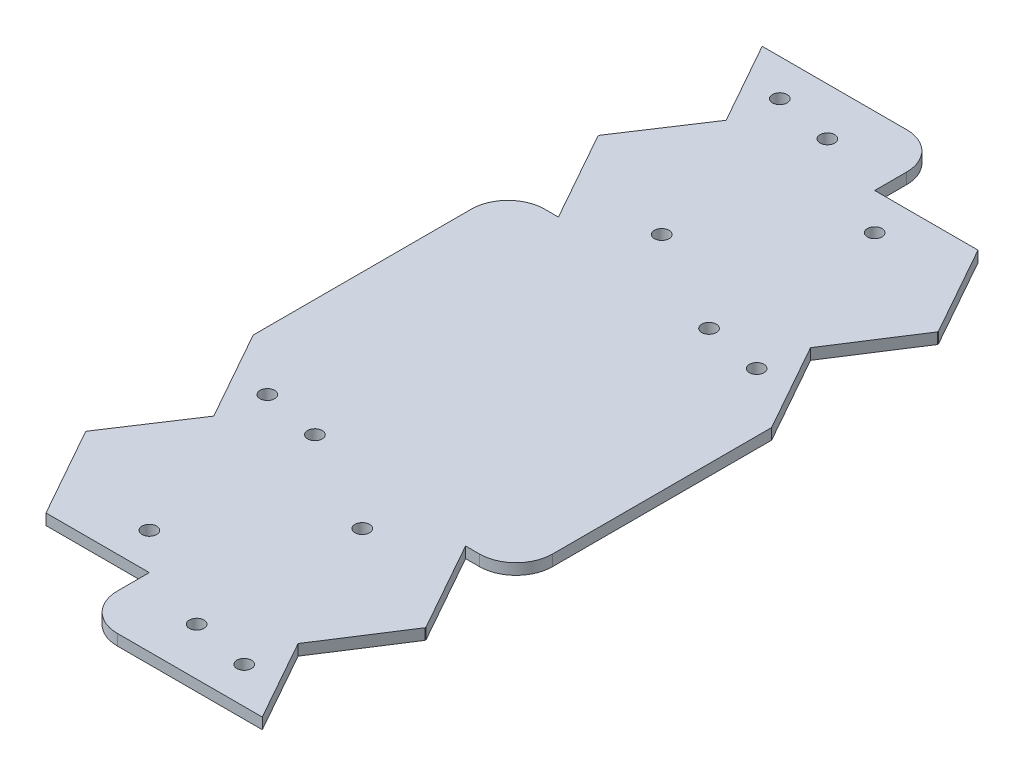
from build123d import *

# Parameters (mm, degrees)
SKETCH1_W           = 92.7
SKETCH1_H           = 227
BOSS_EXTRUDE1_DEPTH = 3
SKETCH3_R           = 2
CUT_EXTRUDE1_DEPTH  = 4
FILLET1_R           = 10


with BuildPart() as part:
    # Sketch1 → Boss-Extrude1 (new body)
    with BuildSketch(Plane(origin=(0, 0, 0), x_dir=(1, 0, 0), z_dir=(0, 1, 0))):
        with Locations((0, -3.5)):
            Rectangle(SKETCH1_W, SKETCH1_H)
    extrude(amount=BOSS_EXTRUDE1_DEPTH)

    # Sketch3 → Cut-Extrude1 (cut, through all)
    with BuildSketch(Plane.XZ):
        Polygon((-46.35, -110), (-45.148132032, -110), (-32.56577351, -87.57595075), (-46.35, -66.656688952), align=None)
        Polygon((-46.35, -41.75), (-46.35, -66.315996364), (-32.56577351, -41.75), align=None)
        with Locations((-30.338884711, -100)):
            Circle(SKETCH3_R)
        with Locations((-14.338884711, -97)):
            Circle(SKETCH3_R)
        Polygon((32.565746646, -91.25), (4.338884711, -91.25), (4.338884711, -110), (46.35, -110), (46.35, -66.68400328), align=None)
        Polygon((32.766055192, -45.29151818), (46.35, -66.340018534), (46.35, -21.082506998), align=None)
        with Locations((30.338884711, -33)):
            Circle(SKETCH3_R)
        with Locations((14.338884711, -36)):
            Circle(SKETCH3_R)
        with Locations((14.338884711, -81.25)):
            Circle(SKETCH3_R)
        Polygon((-46.35, 117), (-46.35, 73.684003636), (-32.56577351, 98.25), (-4.338884711, 98.25), (-4.338884711, 117), align=None)
        Polygon((-46.35, 73.343311048), (-46.35, 27.858052887), (-32.56577351, 52.42404925), align=None)
        Polygon((32.565746646, 48.75), (46.35, 48.75), (46.35, 73.31599672), align=None)
        Polygon((32.766055192, 94.70848182), (46.35, 73.659981466), (46.35, 117), (45.274073399, 117), align=None)
        with Locations((14.338884711, 58.75)):
            Circle(SKETCH3_R)
        with Locations((14.338884711, 104)):
            Circle(SKETCH3_R)
        with Locations((30.338884711, 107)):
            Circle(SKETCH3_R)
        with Locations((-14.338884711, 43)):
            Circle(SKETCH3_R)
        with Locations((-30.338884711, 40)):
            Circle(SKETCH3_R)
        with Locations((-14.338884711, 88.25)):
            Circle(SKETCH3_R)
        with Locations((-14.338884711, -51.75)):
            Circle(SKETCH3_R)
    extrude(amount=-CUT_EXTRUDE1_DEPTH, mode=Mode.SUBTRACT)

    # Fillet1
    fillet1_edges = [part.edges().sort_by_distance(p)[0] for p in [
        (46.35, 1.5, 48.75),
        (-4.338884711, 1.5, 117),
        (4.338884711, 1.5, -110),
        (-46.35, 1.5, -41.75),
    ]]
    fillet(fillet1_edges, radius=FILLET1_R)


solid = part.part
